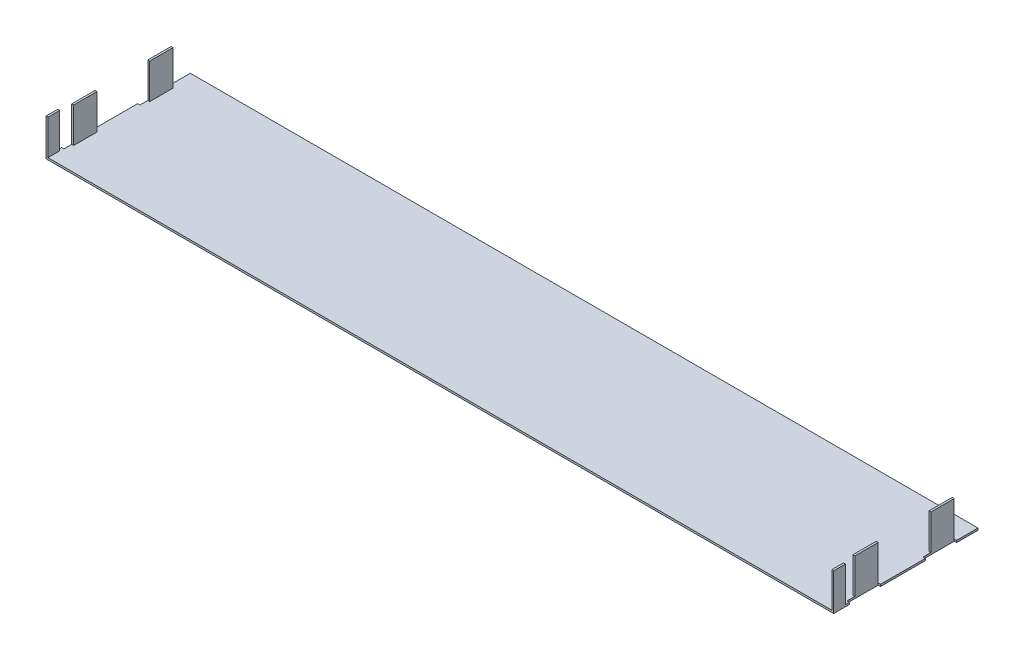
from build123d import *

# Parameters (mm, degrees)
SKETCH1_W                      = 101
SKETCH1_H                      = 37
BOSS_MAINBRIDGERIGHTHALF_DEPTH = 0.5
SKETCH2_W                      = 0.5
SKETCH2_H                      = 3
SKETCH2_H_2                    = 6
BOSS_METALTABS_DEPTH           = 9
SKETCH3_W                      = 0.6
SKETCH3_H                      = 8
CUT_EXTRUDE1_DEPTH             = 1.5


with BuildPart() as part:
    # Sketch1 → Boss-MainBridgeRightHalf (new body)
    with BuildSketch(Plane(origin=(0, 0, 0), x_dir=(1, 0, 0), z_dir=(0, 1, 0))):
        with Locations((50.5, 18.5)):
            Rectangle(SKETCH1_W, SKETCH1_H)
    boss_mainbridgerighthalf = extrude(amount=BOSS_MAINBRIDGERIGHTHALF_DEPTH)

    # Sketch2 → Boss-MetalTabs (add)
    with BuildSketch(Plane(origin=(0, 0.5, 0), x_dir=(1, 0, 0), z_dir=(0, 1, 0))):
        with Locations((100.75, 1.5)):
            Rectangle(SKETCH2_W, SKETCH2_H)
        with Locations((100.15, 28.5)):
            Rectangle(SKETCH2_W, SKETCH2_H_2)
        with Locations((100.15, 9)):
            Rectangle(SKETCH2_W, SKETCH2_H_2)
    boss_metaltabs = extrude(amount=BOSS_METALTABS_DEPTH)

    # Sketch3 → Cut-Extrude1 (cut, through all)
    with BuildSketch(Plane(origin=(0, 0.5, 0), x_dir=(1, 0, 0), z_dir=(0, 1, 0))):
        with Locations((100.7, 27.5)):
            Rectangle(SKETCH3_W, SKETCH3_H)
        with Locations((100.7, 8)):
            Rectangle(SKETCH3_W, SKETCH3_H)
    cut_extrude1 = extrude(amount=-CUT_EXTRUDE1_DEPTH, mode=Mode.SUBTRACT)

    # Mirror1: Boss-MainBridgeRightHalf, Boss-MetalTabs, Cut-Extrude1 across plane
    add(boss_mainbridgerighthalf.mirror(Plane(origin=(0, 0.5, 0), x_dir=(0, 0, 1), z_dir=(1, 0, 0))))
    add(boss_metaltabs.mirror(Plane(origin=(0, 0.5, 0), x_dir=(0, 0, 1), z_dir=(1, 0, 0))))
    add(cut_extrude1.mirror(Plane(origin=(0, 0.5, 0), x_dir=(0, 0, 1), z_dir=(1, 0, 0))), mode=Mode.SUBTRACT)


solid = part.part
